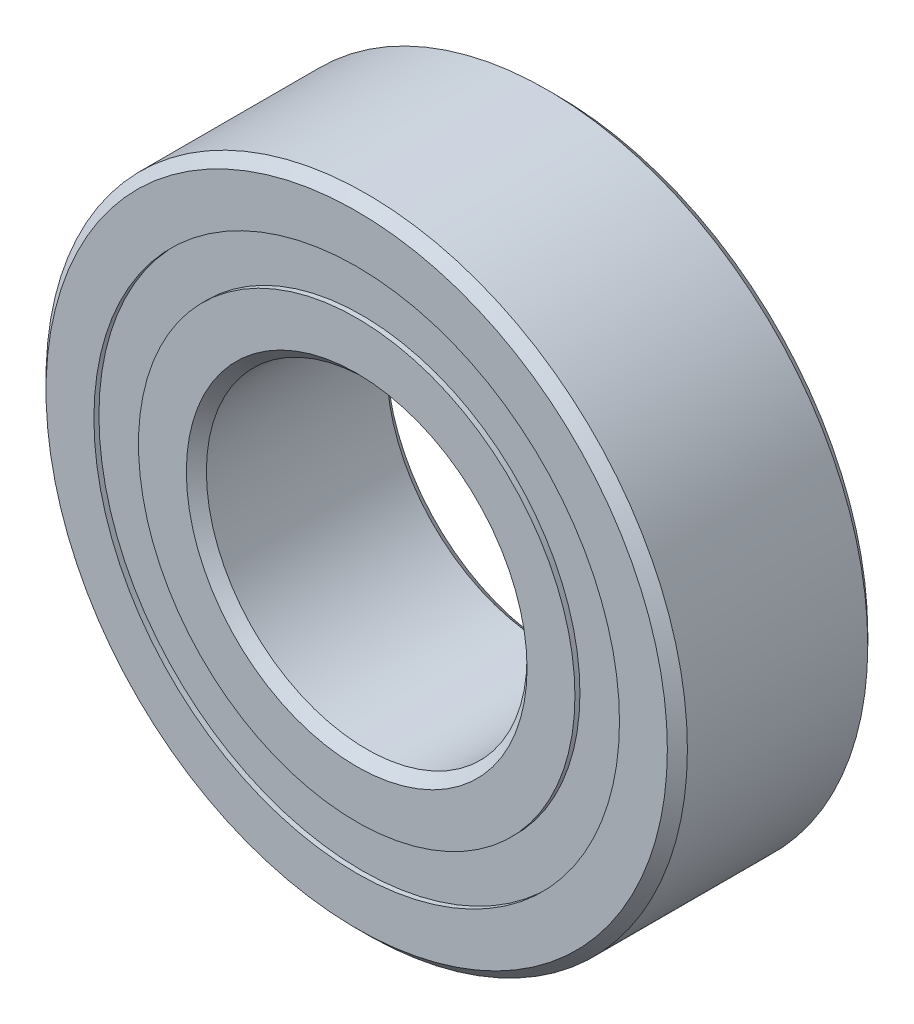
from build123d import *

# Parameters (mm, degrees)
CIRPATTERN1_COUNT = 14
SKETCH5_W         = 1.132740013
SKETCH5_H         = 1.111111112


with BuildPart() as part:
    # Sketch1 → Revolve1 (revolve)
    with BuildSketch(Plane(origin=(0, 0, 0), x_dir=(0, 0, -1), z_dir=(1, 0, 0))):
        with BuildLine():
            Line((2.25, 8), (-2.25, 8))
            Line((-2.25, 8), (-2.5, 7.75))
            Line((-2.5, 7.75), (-2.5, 6.555555556))
            Line((-2.5, 6.555555556), (-1.111111111, 6.555555556))
            ThreePointArc((-1.111111111, 6.555555556), (0, 7.242259987), (1.111111111, 6.555555556))
            Line((1.111111111, 6.555555556), (2.5, 6.555555556))
            Line((2.5, 6.555555556), (2.5, 7.75))
            Line((2.5, 7.75), (2.25, 8))
        make_face()
    revolve(axis=Axis((0, 0, 2.5), (0, 0, -1)))


with BuildPart() as body_2:
    # Sketch2 → Revolve2 (revolve)
    with BuildSketch(Plane(origin=(0, 0, 0), x_dir=(0, 0, -1), z_dir=(1, 0, 0))):
        with BuildLine():
            Line((-2.5, 5.444444444), (-1.111111111, 5.444444444))
            ThreePointArc((-1.111111111, 5.444444444), (0, 4.757740013), (1.111111111, 5.444444444))
            Line((1.111111111, 5.444444444), (2.5, 5.444444444))
            Line((2.5, 5.444444444), (2.5, 4.25))
            Line((2.5, 4.25), (2.25, 4))
            Line((2.25, 4), (-2.25, 4))
            Line((-2.25, 4), (-2.5, 4.25))
            Line((-2.5, 4.25), (-2.5, 5.444444444))
        make_face()
    revolve(axis=Axis((0, 0, 2.5), (0, 0, -1)))


with BuildPart() as body_3:
    # Sketch3 → Revolve3 (revolve)
    with BuildSketch(Plane(origin=(0, 0, 0), x_dir=(0, 0, -1), z_dir=(1, 0, 0))):
        with BuildLine():
            Line((-1.242259987, 6), (1.242259987, 6))
            ThreePointArc((1.242259987, 6), (0, 7.242259987), (-1.242259987, 6))
        make_face()
    revolve(axis=Axis((0, 6, 1.242259987), (0, 0, -1)))


with BuildPart() as cirpattern1_1:
    # CirPattern1: pattern copy
    add(body_3.part.rotate(Axis((0, 0, -2.5), (0, 0, 1)), 1 * 360 / CIRPATTERN1_COUNT))


with BuildPart() as cirpattern1_2:
    # CirPattern1: pattern copy
    add(body_3.part.rotate(Axis((0, 0, -2.5), (0, 0, 1)), 2 * 360 / CIRPATTERN1_COUNT))


with BuildPart() as cirpattern1_3:
    # CirPattern1: pattern copy
    add(body_3.part.rotate(Axis((0, 0, -2.5), (0, 0, 1)), 3 * 360 / CIRPATTERN1_COUNT))


with BuildPart() as cirpattern1_4:
    # CirPattern1: pattern copy
    add(body_3.part.rotate(Axis((0, 0, -2.5), (0, 0, 1)), 4 * 360 / CIRPATTERN1_COUNT))


with BuildPart() as cirpattern1_5:
    # CirPattern1: pattern copy
    add(body_3.part.rotate(Axis((0, 0, -2.5), (0, 0, 1)), 5 * 360 / CIRPATTERN1_COUNT))


with BuildPart() as cirpattern1_6:
    # CirPattern1: pattern copy
    add(body_3.part.rotate(Axis((0, 0, -2.5), (0, 0, 1)), 6 * 360 / CIRPATTERN1_COUNT))


with BuildPart() as cirpattern1_7:
    # CirPattern1: pattern copy
    add(body_3.part.rotate(Axis((0, 0, -2.5), (0, 0, 1)), 7 * 360 / CIRPATTERN1_COUNT))


with BuildPart() as cirpattern1_8:
    # CirPattern1: pattern copy
    add(body_3.part.rotate(Axis((0, 0, -2.5), (0, 0, 1)), 8 * 360 / CIRPATTERN1_COUNT))


with BuildPart() as cirpattern1_9:
    # CirPattern1: pattern copy
    add(body_3.part.rotate(Axis((0, 0, -2.5), (0, 0, 1)), 9 * 360 / CIRPATTERN1_COUNT))


with BuildPart() as cirpattern1_10:
    # CirPattern1: pattern copy
    add(body_3.part.rotate(Axis((0, 0, -2.5), (0, 0, 1)), 10 * 360 / CIRPATTERN1_COUNT))


with BuildPart() as cirpattern1_11:
    # CirPattern1: pattern copy
    add(body_3.part.rotate(Axis((0, 0, -2.5), (0, 0, 1)), 11 * 360 / CIRPATTERN1_COUNT))


with BuildPart() as cirpattern1_12:
    # CirPattern1: pattern copy
    add(body_3.part.rotate(Axis((0, 0, -2.5), (0, 0, 1)), 12 * 360 / CIRPATTERN1_COUNT))


with BuildPart() as cirpattern1_13:
    # CirPattern1: pattern copy
    add(body_3.part.rotate(Axis((0, 0, -2.5), (0, 0, 1)), 13 * 360 / CIRPATTERN1_COUNT))


with BuildPart() as body_17:
    # Sketch5 → Revolve5 (revolve)
    with BuildSketch(Plane(origin=(0, 0, 0), x_dir=(0, 0, -1), z_dir=(1, 0, 0))):
        with Locations((-1.808629994, 6)):
            Rectangle(SKETCH5_W, SKETCH5_H)
        with Locations((1.808629994, 6)):
            Rectangle(SKETCH5_W, SKETCH5_H)
    revolve(axis=Axis((0, 0, 2.5), (0, 0, -1)))


solid = Compound([part.part, body_2.part, body_3.part, cirpattern1_1.part, cirpattern1_2.part, cirpattern1_3.part, cirpattern1_4.part, cirpattern1_5.part, cirpattern1_6.part, cirpattern1_7.part, cirpattern1_8.part, cirpattern1_9.part, cirpattern1_10.part, cirpattern1_11.part, cirpattern1_12.part, cirpattern1_13.part, body_17.part])
